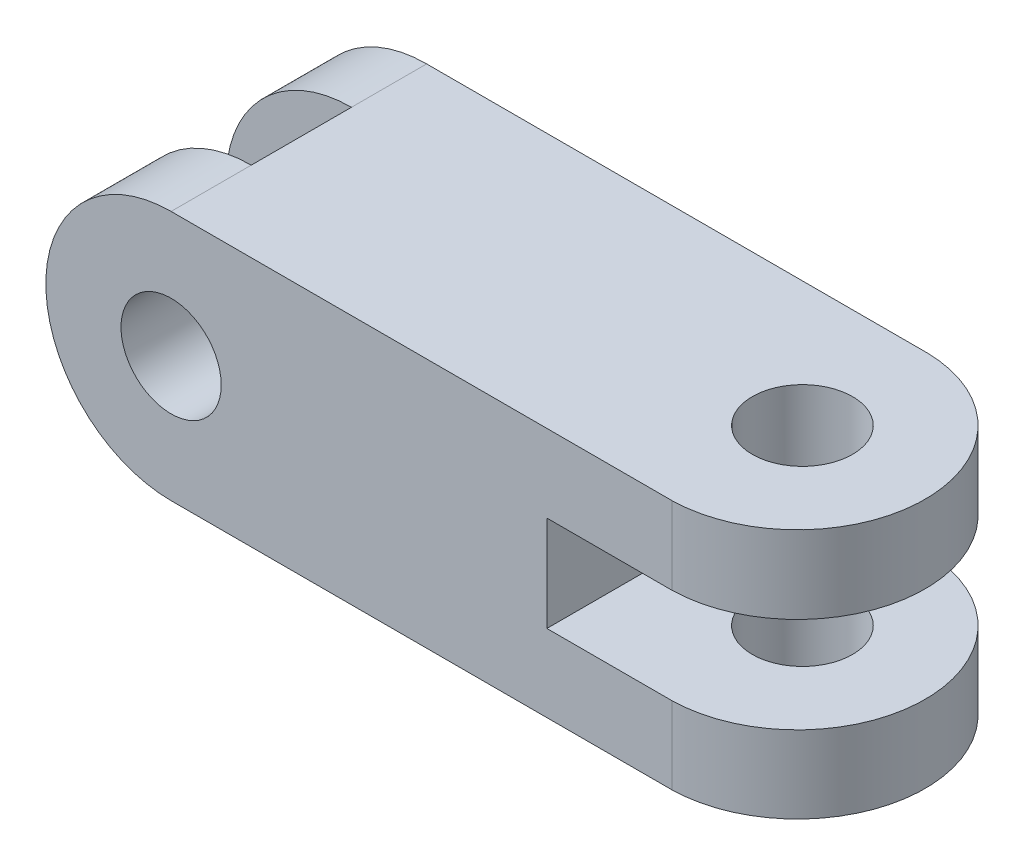
from build123d import *

# Parameters (mm, degrees)
SKETCH1_R                = 10
BOSS_EXTRUDE1_DEPTH      = 50
BOSS_EXTRUDE1_DEPTH_BACK = 1
SKETCH2_W                = 25
SKETCH2_H                = 20
SKETCH2_R                = 10
CUT_EXTRUDE3_DEPTH       = 50


with BuildPart() as part:
    # Sketch1 → Boss-Extrude1 (new body, two sides)
    with BuildSketch(Plane.XY) as boss_extrude1_sk:
        with BuildLine():
            Line((90.467312071, -12.290554593), (40.467312071, -12.290554593))
            Line((40.467312071, -12.290554593), (40.467312071, -31.373570191))
            Line((40.467312071, -31.373570191), (90.467312071, -31.373570191))
            Line((90.467312071, -31.373570191), (90.467312071, -46.790554593))
            Line((90.467312071, -46.790554593), (-34.532687929, -46.790554593))
            ThreePointArc((-34.532687929, -46.790554593), (-59.532687929, -21.790554593), (-34.532687929, 3.209445407))
            Line((-34.532687929, 3.209445407), (90.467312071, 3.209445407))
            Line((90.467312071, 3.209445407), (90.467312071, -12.290554593))
        make_face()
        with Locations((-34.532687929, -21.790554593)):
            Circle(SKETCH1_R, mode=Mode.SUBTRACT)
    extrude(amount=BOSS_EXTRUDE1_DEPTH)
    extrude(boss_extrude1_sk.sketch, amount=-BOSS_EXTRUDE1_DEPTH_BACK)

    # Sketch2 → Cut-Extrude3 (cut)
    with BuildSketch(Plane(origin=(0, 3.209445407, 0), x_dir=(1, 0, 0), z_dir=(0, 1, 0))):
        with Locations((-47.032687929, -24)):
            Rectangle(SKETCH2_W, SKETCH2_H)
        with Locations((65.467312071, -24)):
            Circle(SKETCH2_R)
        with BuildLine():
            ThreePointArc((90.467312071, -24.5), (83.174739834, -42.355321336), (65.467312071, -50))
            Line((65.467312071, -50), (90.467312071, -50))
            Line((90.467312071, -50), (90.467312071, -24.5))
        make_face()
        with BuildLine():
            Line((90.467312071, 1), (65.467312071, 1))
            ThreePointArc((65.467312071, 1), (83.174739834, -6.644678664), (90.467312071, -24.5))
            Line((90.467312071, -24.5), (90.467312071, 1))
        make_face()
    extrude(amount=-CUT_EXTRUDE3_DEPTH, mode=Mode.SUBTRACT)


solid = part.part
